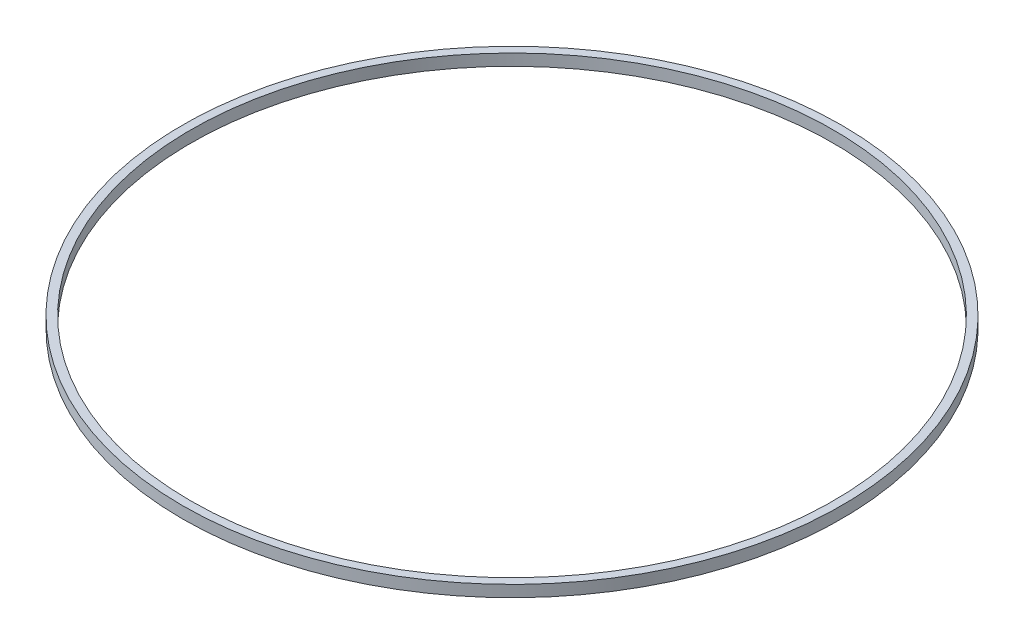
from build123d import *

# Parameters (mm, degrees)
SKETCH1_R           = 100
SKETCH1_R_2         = 97.5
BOSS_EXTRUDE1_DEPTH = 3.5


with BuildPart() as part:
    # Sketch1 → Boss-Extrude1 (new body)
    with BuildSketch(Plane(origin=(0, 0, 0), x_dir=(1, 0, 0), z_dir=(0, 1, 0))):
        Circle(SKETCH1_R)
        Circle(SKETCH1_R_2, mode=Mode.SUBTRACT)
    extrude(amount=BOSS_EXTRUDE1_DEPTH)


solid = part.part
